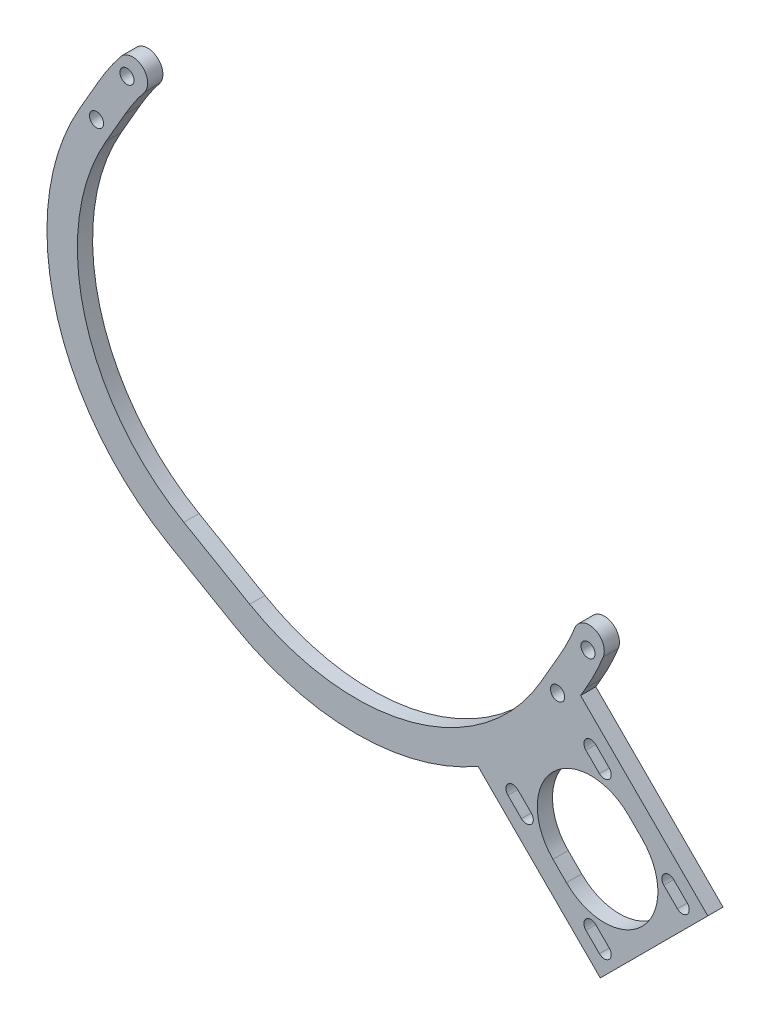
from build123d import *

# Parameters (mm, degrees)
BOSS_EXTRUDE1_DEPTH   = 3.175
BOSS_EXTRUDE2_DEPTH   = 3.175
F_4_CLEARANCE_HOLE1_D = 2.9464


with BuildPart() as part:
    # Sketch1 → Boss-Extrude1 (new body)
    with BuildSketch(Plane(origin=(0, 0, -14.15699402), x_dir=(-1, 0, 0), z_dir=(0, 0, -1))):
        with BuildLine():
            Line((-49.172312317, -34.502108483), (-53.141062317, -27.628031841))
            ThreePointArc((-53.141062317, -27.628031841), (-55.063803638, -24.012221257), (-56.72992661, -20.271224785))
            ThreePointArc((-56.72992661, -20.271224785), (-54.976138042, -16.13776671), (-50.842679967, -17.891555277))
            ThreePointArc((-50.842679967, -17.891555277), (-49.356678398, -21.228119699), (-47.641801003, -24.453031841))
            Line((-47.641801003, -24.453031841), (-43.673051003, -31.327108483))
            ThreePointArc((-43.673051003, -31.327108483), (-16.68272836, -52.037511462), (17.046778195, -47.596937682))
            Line((17.046778195, -47.596937682), (23.920854837, -43.628187682))
            Line((23.920854837, -43.628187682), (30.79493148, -39.659437682))
            ThreePointArc((30.79493148, -39.659437682), (51.505334458, -12.669115038), (47.064760678, 21.060391517))
            Line((47.064760678, 21.060391517), (43.096010678, 27.934468159))
            ThreePointArc((43.096010678, 27.934468159), (41.160593535, 31.032051618), (39.01404477, 33.987248938))
            ThreePointArc((39.01404477, 33.987248938), (39.561948355, 38.44382292), (44.018522337, 37.895919335))
            ThreePointArc((44.018522337, 37.895919335), (46.425258832, 34.58251628), (48.595271992, 31.109468159))
            Line((48.595271992, 31.109468159), (52.564021992, 24.235391517))
            ThreePointArc((52.564021992, 24.235391517), (57.638963455, -14.312615975), (33.96993148, -45.158698996))
            Line((33.96993148, -45.158698996), (27.095854837, -49.127448996))
            Line((27.095854837, -49.127448996), (20.221778195, -53.096198996))
            ThreePointArc((20.221778195, -53.096198996), (-18.326229296, -58.171140459), (-49.172312317, -34.502108483))
        make_face()
    extrude(amount=BOSS_EXTRUDE1_DEPTH)

    # Sketch6 → Boss-Extrude2 (add)
    with BuildSketch(Plane.XY.offset(-14.15699402)):
        Polygon((78.577241059, -56.126600757), (56.126600757, -78.577241059), (27.345741417, -49.796381719), (49.796381719, -27.345741417), align=None)
        with BuildLine():
            Line((62.053569797, -46.248319024), (64.873370219, -49.068119446))
            ThreePointArc((64.873370219, -49.068119446), (64.873370219, -64.873370219), (49.068119446, -64.873370219))
            Line((49.068119446, -64.873370219), (46.248319024, -62.053569797))
            ThreePointArc((46.248319024, -62.053569797), (46.248319024, -46.248319024), (62.053569797, -46.248319024))
        make_face(mode=Mode.SUBTRACT)
        with BuildLine():
            Line((55.946995634, -74.266718121), (53.127195212, -71.446917699))
            ThreePointArc((53.127195212, -71.446917699), (53.127195212, -69.399419304), (55.174693608, -69.399419304))
            Line((55.174693608, -69.399419304), (57.99449403, -72.219219726))
            ThreePointArc((57.99449403, -72.219219726), (57.99449403, -74.266718121), (55.946995634, -74.266718121))
        make_face(mode=Mode.SUBTRACT)
        with BuildLine():
            Line((38.902469516, -53.127195212), (41.722269938, -55.946995634))
            ThreePointArc((41.722269938, -55.946995634), (41.722269938, -57.99449403), (39.674771543, -57.99449403))
            Line((39.674771543, -57.99449403), (36.854971121, -55.174693608))
            ThreePointArc((36.854971121, -55.174693608), (36.854971121, -53.127195212), (38.902469516, -53.127195212))
        make_face(mode=Mode.SUBTRACT)
        with BuildLine():
            Line((55.174693608, -36.854971121), (57.99449403, -39.674771543))
            ThreePointArc((57.99449403, -39.674771543), (57.99449403, -41.722269938), (55.946995634, -41.722269938))
            Line((55.946995634, -41.722269938), (53.127195212, -38.902469516))
            ThreePointArc((53.127195212, -38.902469516), (53.127195212, -36.854971121), (55.174693608, -36.854971121))
        make_face(mode=Mode.SUBTRACT)
        with BuildLine():
            Line((71.446917699, -53.127195212), (74.266718121, -55.946995634))
            ThreePointArc((74.266718121, -55.946995634), (74.266718121, -57.99449403), (72.219219726, -57.99449403))
            Line((72.219219726, -57.99449403), (69.399419304, -55.174693608))
            ThreePointArc((69.399419304, -55.174693608), (69.399419304, -53.127195212), (71.446917699, -53.127195212))
        make_face(mode=Mode.SUBTRACT)
    extrude(amount=-BOSS_EXTRUDE2_DEPTH)

    # 4 Clearance Hole1 (through all)
    with Locations(Plane(origin=(0, 0, -17.33199402), x_dir=(-1, 0, 0), z_dir=(0, 0, -1))):
        with Locations((-53.56643166, -20.541270527), (-47.21643166, -31.539793155), (42.670641335, 35.021229473), (49.020641335, 24.022706845)):
            Hole(F_4_CLEARANCE_HOLE1_D / 2)


solid = part.part
